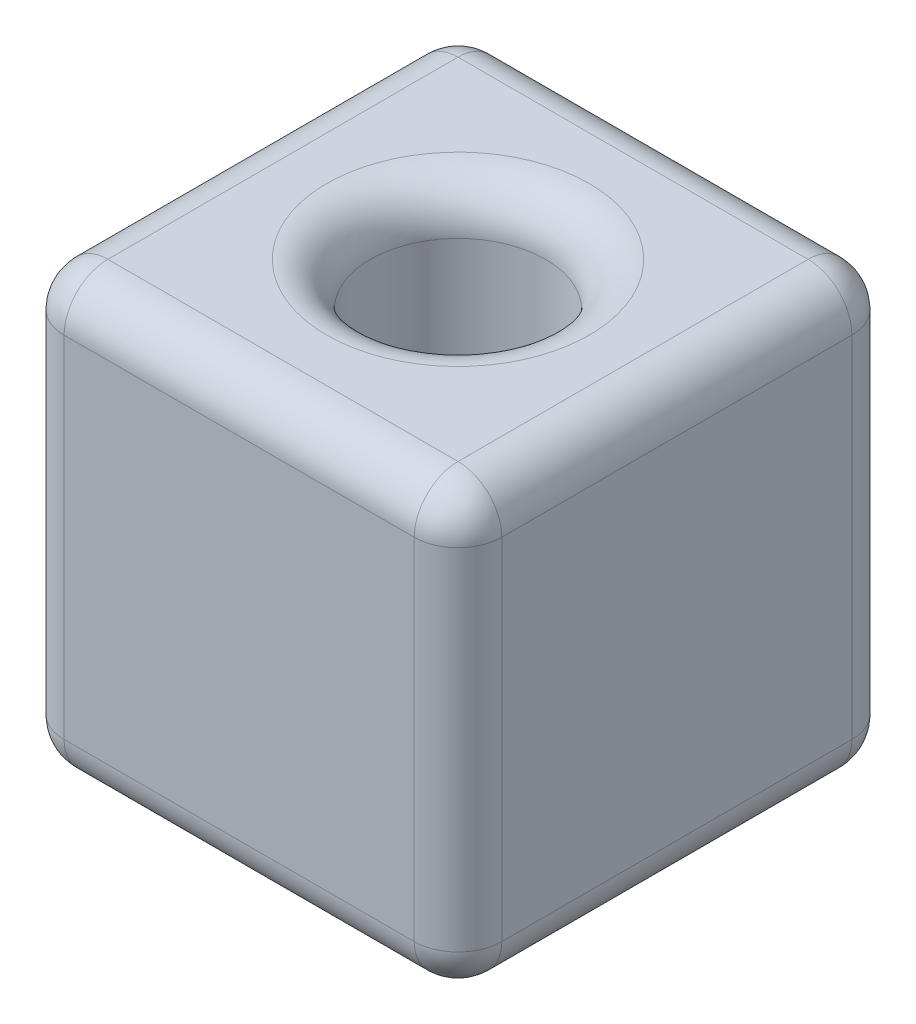
from build123d import *

# Parameters (mm, degrees)
CROQUIS1_W              = 5
CROQUIS1_H              = 5
SALIENTE_EXTRUIR1_DEPTH = 2.5
CROQUIS2_R              = 1
CORTAR_EXTRUIR1_DEPTH   = 6
REDONDEO1_R             = 0.5


with BuildPart() as part:
    # Croquis1 → Saliente-Extruir1 (new body, symmetric)
    with BuildSketch(Plane(origin=(0, 0, 0), x_dir=(1, 0, 0), z_dir=(0, 1, 0))):
        Rectangle(CROQUIS1_W, CROQUIS1_H)
    extrude(amount=SALIENTE_EXTRUIR1_DEPTH, both=True)

    # Croquis2 → Cortar-Extruir1 (cut, through all)
    with BuildSketch(Plane(origin=(0, 2.5, 0), x_dir=(1, 0, 0), z_dir=(0, 1, 0))):
        Circle(CROQUIS2_R)
    extrude(amount=-CORTAR_EXTRUIR1_DEPTH, mode=Mode.SUBTRACT)

    # Redondeo1
    redondeo1_edges = [part.edges().sort_by_distance(p)[0] for p in [
        (-2.5, 2.5, 0),
        (0, 2.5, 2.5),
        (-1, -2.5, 0),
        (-1, 2.5, 0),
        (2.5, 2.5, 0),
        (0, -2.5, 2.5),
        (-2.5, -2.5, 0),
        (0, -2.5, -2.5),
        (2.5, -2.5, 0),
        (0, 2.5, -2.5),
        (2.5, 0, 2.5),
        (-2.5, 0, 2.5),
        (-2.5, 0, -2.5),
        (2.5, 0, -2.5),
    ]]
    fillet(redondeo1_edges, radius=REDONDEO1_R)


solid = part.part
